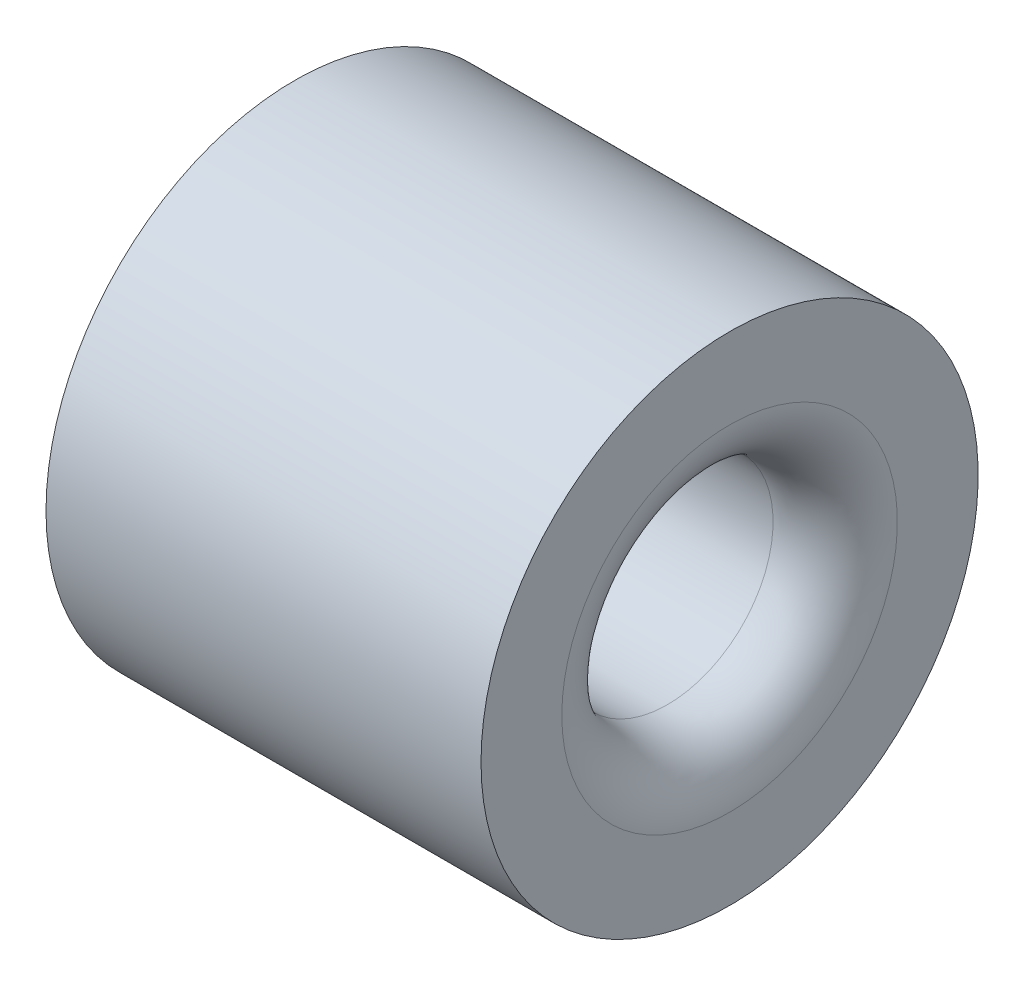
from build123d import *

# Parameters (mm, degrees)
SKIZZE1_W     = 3.5
SKIZZE1_H     = 1.15
VERRUNDUNG1_R = 0.5


with BuildPart() as part:
    # Skizze1 → Rotation1 (revolve)
    with BuildSketch(Plane.XY):
        with Locations((1.75, 1.425)):
            Rectangle(SKIZZE1_W, SKIZZE1_H)
    revolve(axis=Axis((0, 0, 0), (1, 0, 0)))

    # Verrundung1
    verrundung1_edges = [part.edges().sort_by_distance(p)[0] for p in [
        (3.5, -0.85, 0),
        (0, -0.85, 0),
    ]]
    fillet(verrundung1_edges, radius=VERRUNDUNG1_R)


solid = part.part
